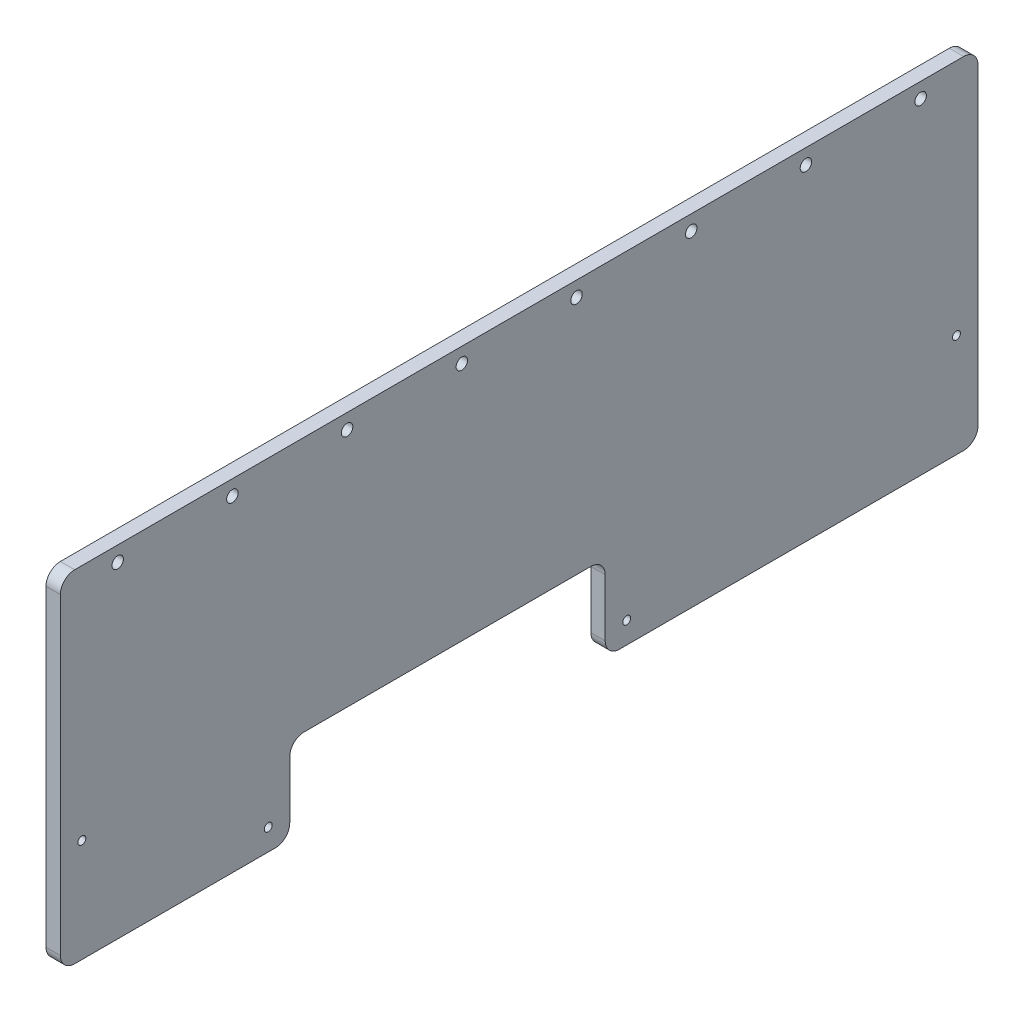
from build123d import *

# Parameters (mm, degrees)
BOSS_EXTRUDE1_DEPTH = 6.35
SKETCH3_R           = 3.96875
CUT_EXTRUDE1_DEPTH  = 7.35
SKETCH5_W           = 6.35
SKETCH5_H           = 12.7
CUT_EXTRUDE3_DEPTH  = 7.35
LPATTERN1_COUNT     = 16
LPATTERN1_PITCH     = 25.4
SKETCH6_W           = 6.35
SKETCH6_H           = 12.7
CUT_EXTRUDE4_DEPTH  = 7.35
LPATTERN2_COUNT     = 11
LPATTERN2_PITCH     = 25.4
SKETCH7_W           = 6.35
SKETCH7_H           = 12.7
SKETCH7_W_2         = 12.7
SKETCH7_H_2         = 6.35
CUT_EXTRUDE5_DEPTH  = 7.35
CUT_EXTRUDE6_DEPTH  = 7.35
LPATTERN3_COUNT     = 10
LPATTERN3_PITCH     = 25.4
SKETCH9_W           = 12.7
SKETCH9_H           = 6.35
CUT_EXTRUDE7_DEPTH  = 7.35
LPATTERN4_COUNT     = 8
LPATTERN4_PITCH     = 25.4
SKETCH10_R          = 3.175
CUT_EXTRUDE8_DEPTH  = 7.35
SKETCH11_R          = 3.96875
CUT_EXTRUDE9_DEPTH  = 7.35
SKETCH12_W          = 6.35
SKETCH12_H          = 12.7
CUT_EXTRUDE13_DEPTH = 7.35
CUT_EXTRUDE15_DEPTH = 7.35
CUT_EXTRUDE16_DEPTH = 7.35
SKETCH17_W          = 12.7
SKETCH17_H          = 6.35
CUT_EXTRUDE17_DEPTH = 7.35
LPATTERN5_COUNT     = 17
LPATTERN5_PITCH     = 25.4
LPATTERN6_COUNT     = 2
LPATTERN6_PITCH     = 120.65
SKETCH18_W          = 12.7
SKETCH18_H          = 6.35
CUT_EXTRUDE18_DEPTH = 7.35
LPATTERN7_COUNT     = 5
LPATTERN7_PITCH     = 25.4
CUT_EXTRUDE19_DEPTH = 7.35
SKETCH20_W          = 101.6
SKETCH20_H          = 57.15
CUT_EXTRUDE20_DEPTH = 7.35
CUT_EXTRUDE21_DEPTH = 7.35
CUT_EXTRUDE22_DEPTH = 7.35
BOSS_EXTRUDE4_DEPTH = 6.35
BOSS_EXTRUDE5_DEPTH = 6.35
SKETCH29_R          = 2.54
CUT_EXTRUDE23_DEPTH = 7.35
SKETCH30_R          = 1.75
CUT_EXTRUDE24_DEPTH = 7.35
FILLET2_R           = 6.35


with BuildPart() as part:
    # Sketch2 → Boss-Extrude1 (new body)
    with BuildSketch(Plane(origin=(0, 0, 0), x_dir=(0, 0, -1), z_dir=(1, 0, 0))):
        Polygon((0, 0), (0, 294.450076882), (215.9, 419.1), (431.8, 419.1), (431.8, 0), (241.3, 0), (241.3, 38.1), (127, 38.1), (127, 0), align=None)
    extrude(amount=BOSS_EXTRUDE1_DEPTH)

    # Sketch3 → Cut-Extrude1 (cut, through all)
    with BuildSketch(Plane(origin=(6.35, 0, 0), x_dir=(0, 0, -1), z_dir=(1, 0, 0))):
        with Locations((63.5, 38.1)):
            Circle(SKETCH3_R)
        with Locations((368.3, 38.1)):
            Circle(SKETCH3_R)
    extrude(amount=-CUT_EXTRUDE1_DEPTH, mode=Mode.SUBTRACT)

    # Sketch5 → Cut-Extrude3 (cut, through all)
    with BuildSketch(Plane(origin=(6.35, 0, 0), x_dir=(0, 0, -1), z_dir=(1, 0, 0))):
        with Locations((428.625, 19.05)):
            Rectangle(SKETCH5_W, SKETCH5_H)
    cut_extrude3 = extrude(amount=-CUT_EXTRUDE3_DEPTH, mode=Mode.SUBTRACT)

    # LPattern1: Cut-Extrude3 ×16
    with Locations(*[(0, i * LPATTERN1_PITCH, 0) for i in range(1, LPATTERN1_COUNT)]):
        add(cut_extrude3, mode=Mode.SUBTRACT)

    # Sketch6 → Cut-Extrude4 (cut, through all)
    with BuildSketch(Plane(origin=(6.35, 0, 0), x_dir=(0, 0, -1), z_dir=(1, 0, 0))):
        with Locations((3.175, 19.05)):
            Rectangle(SKETCH6_W, SKETCH6_H)
    cut_extrude4 = extrude(amount=-CUT_EXTRUDE4_DEPTH, mode=Mode.SUBTRACT)

    # LPattern2: Cut-Extrude4 ×11
    with Locations(*[(0, i * LPATTERN2_PITCH, 0) for i in range(1, LPATTERN2_COUNT)]):
        add(cut_extrude4, mode=Mode.SUBTRACT)

    # Sketch7 → Cut-Extrude5 (cut, through all)
    with BuildSketch(Plane(origin=(6.35, 0, 0), x_dir=(0, 0, -1), z_dir=(1, 0, 0))):
        with Locations((123.825, 19.05)):
            Rectangle(SKETCH7_W, SKETCH7_H)
        with Locations((133.35, 41.275)):
            Rectangle(SKETCH7_W_2, SKETCH7_H_2)
        with Locations((158.75, 41.275)):
            Rectangle(SKETCH7_W_2, SKETCH7_H_2)
        with Locations((184.15, 41.275)):
            Rectangle(SKETCH7_W_2, SKETCH7_H_2)
        with Locations((244.475, 19.05)):
            Rectangle(SKETCH7_W, SKETCH7_H)
        with Locations((209.55, 41.275)):
            Rectangle(SKETCH7_W_2, SKETCH7_H_2)
        with Locations((234.95, 41.275)):
            Rectangle(SKETCH7_W_2, SKETCH7_H_2)
    extrude(amount=-CUT_EXTRUDE5_DEPTH, mode=Mode.SUBTRACT)

    # Sketch8 → Cut-Extrude6 (cut, through all)
    with BuildSketch(Plane(origin=(6.35, 0, 0), x_dir=(0, 0, -1), z_dir=(1, 0, 0))):
        Polygon((201.93507044, 411.037344159), (212.933593068, 417.387344159), (216.108593068, 411.888082845), (205.11007044, 405.538082845), align=None)
    cut_extrude6 = extrude(amount=-CUT_EXTRUDE6_DEPTH, mode=Mode.SUBTRACT)

    # LPattern3: Cut-Extrude6 ×10
    with Locations(*[Vector(0, -0.5, 0.866025404) * (i * LPATTERN3_PITCH) for i in range(1, LPATTERN3_COUNT)]):
        add(cut_extrude6, mode=Mode.SUBTRACT)

    # Sketch9 → Cut-Extrude7 (cut, through all)
    with BuildSketch(Plane(origin=(6.35, 0, 0), x_dir=(0, 0, -1), z_dir=(1, 0, 0))):
        with Locations((412.75, 415.925)):
            Rectangle(SKETCH9_W, SKETCH9_H)
    cut_extrude7 = extrude(amount=-CUT_EXTRUDE7_DEPTH, mode=Mode.SUBTRACT)

    # LPattern4: Cut-Extrude7 ×8
    with Locations(*[(0, 0, i * LPATTERN4_PITCH) for i in range(1, LPATTERN4_COUNT)]):
        add(cut_extrude7, mode=Mode.SUBTRACT)

    # Sketch10 → Cut-Extrude8 (cut, through all)
    with BuildSketch(Plane(origin=(6.35, 0, 0), x_dir=(0, 0, -1), z_dir=(1, 0, 0))):
        with Locations((222.25, 273.05)):
            Circle(SKETCH10_R)
        with Locations((222.25, 57.15)):
            Circle(SKETCH10_R)
        with Locations((146.05, 57.15)):
            Circle(SKETCH10_R)
        with Locations((146.05, 273.05)):
            Circle(SKETCH10_R)
    extrude(amount=-CUT_EXTRUDE8_DEPTH, mode=Mode.SUBTRACT)

    # Sketch11 → Cut-Extrude9 (cut, through all)
    with BuildSketch(Plane(origin=(6.35, 0, 0), x_dir=(0, 0, -1), z_dir=(1, 0, 0))):
        with Locations((38.1, 260.35)):
            Circle(SKETCH11_R)
        with Locations((266.7, 260.35)):
            Circle(SKETCH11_R)
    extrude(amount=-CUT_EXTRUDE9_DEPTH, mode=Mode.SUBTRACT)

    # Sketch12 → Cut-Extrude13 (cut, through all)
    with BuildSketch(Plane(origin=(6.35, 0, 0), x_dir=(0, 0, -1), z_dir=(1, 0, 0))):
        with Locations((123.825, 44.45)):
            Rectangle(SKETCH12_W, SKETCH12_H)
        with Locations((123.825, 69.85)):
            Rectangle(SKETCH12_W, SKETCH12_H)
        with Locations((123.825, 95.25)):
            Rectangle(SKETCH12_W, SKETCH12_H)
        with Locations((123.825, 120.65)):
            Rectangle(SKETCH12_W, SKETCH12_H)
    cut_extrude13 = extrude(amount=-CUT_EXTRUDE13_DEPTH, mode=Mode.SUBTRACT)

    # Sketch14 → Cut-Extrude15 (cut, through all)
    with BuildSketch(Plane(origin=(6.35, 0, 0), x_dir=(0, 0, -1), z_dir=(1, 0, 0))):
        Polygon((36.957231019, 315.787344159), (47.955753647, 322.137344159), (51.130753647, 316.638082845), (40.132231019, 310.288082845), align=None)
        Polygon((80.951321531, 341.187344159), (91.949844159, 347.537344159), (95.124844159, 342.038082845), (84.126321531, 335.688082845), align=None)
    extrude(amount=-CUT_EXTRUDE15_DEPTH, mode=Mode.SUBTRACT)

    # Sketch15 → Cut-Extrude16 (cut, through all)
    with BuildSketch(Plane(origin=(6.35, 0, 0), x_dir=(0, 0, -1), z_dir=(1, 0, 0))):
        with BuildLine():
            Line((62.129276275, 322.988082845), (31.558579521, 305.338082845))
            ThreePointArc((31.558579521, 305.338082845), (51.535904978, 302.314952438), (62.501260575, 319.285333297))
            ThreePointArc((62.501260575, 319.285333297), (62.408031035, 321.146027155), (62.129276275, 322.988082845))
        make_face()
        with BuildLine():
            Line((103.698495657, 346.988082845), (73.127798903, 329.338082845))
            ThreePointArc((73.127798903, 329.338082845), (93.10512436, 326.314952438), (104.070479957, 343.285333297))
            ThreePointArc((104.070479957, 343.285333297), (103.977250417, 345.146027155), (103.698495657, 346.988082845))
        make_face()
    extrude(amount=-CUT_EXTRUDE16_DEPTH, mode=Mode.SUBTRACT)

    # Sketch17 → Cut-Extrude17 (cut, through all)
    with BuildSketch(Plane(origin=(6.35, 0, 0), x_dir=(0, 0, -1), z_dir=(1, 0, 0))):
        with Locations((25.4, 142.875)):
            Rectangle(SKETCH17_W, SKETCH17_H)
    cut_extrude17 = extrude(amount=-CUT_EXTRUDE17_DEPTH, mode=Mode.SUBTRACT)

    # LPattern5: Cut-Extrude17 ×17
    with Locations(*[(0, 0, -i * LPATTERN5_PITCH) for i in range(1, LPATTERN5_COUNT)]):
        add(cut_extrude17, mode=Mode.SUBTRACT)

    # LPattern6: Cut-Extrude13 ×2
    with Locations(*[(0, 0, -i * LPATTERN6_PITCH) for i in range(1, LPATTERN6_COUNT)]):
        add(cut_extrude13, mode=Mode.SUBTRACT)

    # Sketch18 → Cut-Extrude18 (cut, through all)
    with BuildSketch(Plane(origin=(6.35, 0, 0), x_dir=(0, 0, -1), z_dir=(1, 0, 0))):
        with Locations((133.35, 117.475)):
            Rectangle(SKETCH18_W, SKETCH18_H)
    cut_extrude18 = extrude(amount=-CUT_EXTRUDE18_DEPTH, mode=Mode.SUBTRACT)

    # LPattern7: Cut-Extrude18 ×5
    with Locations(*[(0, 0, -i * LPATTERN7_PITCH) for i in range(1, LPATTERN7_COUNT)]):
        add(cut_extrude18, mode=Mode.SUBTRACT)

    # Sketch19 → Cut-Extrude19 (cut, through all)
    with BuildSketch(Plane(origin=(6.35, 0, 0), x_dir=(0, 0, -1), z_dir=(1, 0, 0))):
        Polygon((25.4, 279.785380045), (222.705909488, 393.7), (406.4, 393.7), (406.4, 165.1), (25.4, 165.1), align=None)
    extrude(amount=-CUT_EXTRUDE19_DEPTH, mode=Mode.SUBTRACT)

    # Sketch20 → Cut-Extrude20 (cut, through all)
    with BuildSketch(Plane(origin=(6.35, 0, 0), x_dir=(0, 0, -1), z_dir=(1, 0, 0))):
        with Locations((184.15, 79.375)):
            Rectangle(SKETCH20_W, SKETCH20_H)
    extrude(amount=-CUT_EXTRUDE20_DEPTH, mode=Mode.SUBTRACT)

    # Sketch21 → Cut-Extrude21 (cut, through all)
    with BuildSketch(Plane(origin=(6.35, 0, 0), x_dir=(0, 0, -1), z_dir=(1, 0, 0))):
        Polygon((266.7, 25.4), (308.202954744, 25.4), (406.4, 82.094090512), (406.4, 133.35), (266.7, 133.35), align=None)
        Polygon((25.4, 133.35), (25.4, 82.094090512), (101.6, 38.1), (101.6, 133.35), align=None)
        Polygon((25.4, 38.1), (25.4, 25.4), (47.397045256, 25.4), align=None)
    extrude(amount=-CUT_EXTRUDE21_DEPTH, mode=Mode.SUBTRACT)

    # Sketch22 → Cut-Extrude22 (cut, through all)
    with BuildSketch(Plane(origin=(6.35, 0, 0), x_dir=(0, 0, -1), z_dir=(1, 0, 0))):
        Polygon((384.402954744, 25.4), (406.4, 38.1), (406.4, 25.4), align=None)
    extrude(amount=-CUT_EXTRUDE22_DEPTH, mode=Mode.SUBTRACT)

    # Sketch26 → Boss-Extrude4 (add, through all)
    with BuildSketch(Plane(origin=(6.35, 0, 0), x_dir=(0, 0, -1), z_dir=(1, 0, 0))):
        Polygon((266.7, 133.35), (266.7, 126.280871047), (278.944090512, 133.35), align=None)
        Polygon((89.355909488, 133.35), (101.6, 126.280871047), (101.6, 133.35), align=None)
        Polygon((266.7, 32.469128953), (278.944090512, 25.4), (266.7, 25.4), align=None)
        Polygon((133.35, 107.95), (133.35, 100.880871047), (145.594090512, 107.95), align=None)
        Polygon((234.95, 107.95), (222.705909488, 107.95), (234.95, 100.880871047), align=None)
        Polygon((133.35, 50.8), (145.594090512, 50.8), (133.35, 57.869128953), align=None)
        Polygon((234.95, 50.8), (222.705909488, 50.8), (234.95, 57.869128953), align=None)
    extrude(amount=-BOSS_EXTRUDE4_DEPTH)


with BuildPart() as body_2:
    # Sketch27 → Boss-Extrude5 (new body)
    with BuildSketch(Plane(origin=(6.35, 0, 0), x_dir=(0, 0, -1), z_dir=(1, 0, 0))):
        Polygon((12.7, 163.83), (12.7, 12.7), (114.3, 12.7), (114.3, 50.8), (254, 50.8), (254, 12.7), (419.1, 12.7), (419.1, 163.83), align=None)
    extrude(amount=-BOSS_EXTRUDE5_DEPTH)

    # Sketch29 → Cut-Extrude23 (cut, through all)
    with BuildSketch(Plane(origin=(6.35, 0, 0), x_dir=(0, 0, -1), z_dir=(1, 0, 0))):
        with Locations((38.1, 157.1625)):
            Circle(SKETCH29_R)
        with Locations((88.9, 157.1625)):
            Circle(SKETCH29_R)
        with Locations((139.7, 157.1625)):
            Circle(SKETCH29_R)
        with Locations((190.5, 157.1625)):
            Circle(SKETCH29_R)
        with Locations((241.3, 157.1625)):
            Circle(SKETCH29_R)
        with Locations((292.1, 157.1625)):
            Circle(SKETCH29_R)
        with Locations((342.9, 157.1625)):
            Circle(SKETCH29_R)
        with Locations((393.7, 157.1625)):
            Circle(SKETCH29_R)
    extrude(amount=-CUT_EXTRUDE23_DEPTH, mode=Mode.SUBTRACT)

    # Sketch30 → Cut-Extrude24 (cut, through all)
    with BuildSketch(Plane(origin=(6.35, 0, 0), x_dir=(0, 0, -1), z_dir=(1, 0, 0))):
        with Locations((22.225, 58.42)):
            Circle(SKETCH30_R)
        with Locations((104.775, 22.225)):
            Circle(SKETCH30_R)
        with Locations((263.525, 22.225)):
            Circle(SKETCH30_R)
        with Locations((409.575, 58.42)):
            Circle(SKETCH30_R)
    extrude(amount=-CUT_EXTRUDE24_DEPTH, mode=Mode.SUBTRACT)

    # Fillet2
    fillet2_edges = [body_2.edges().sort_by_distance(p)[0] for p in [
        (3.175, 163.83, -419.1),
        (3.175, 12.7, -419.1),
        (3.175, 12.7, -254),
        (3.175, 50.8, -254),
        (3.175, 50.8, -114.3),
        (3.175, 12.7, -114.3),
        (3.175, 12.7, -12.7),
        (3.175, 163.83, -12.7),
    ]]
    fillet(fillet2_edges, radius=FILLET2_R)


solid = body_2.part
